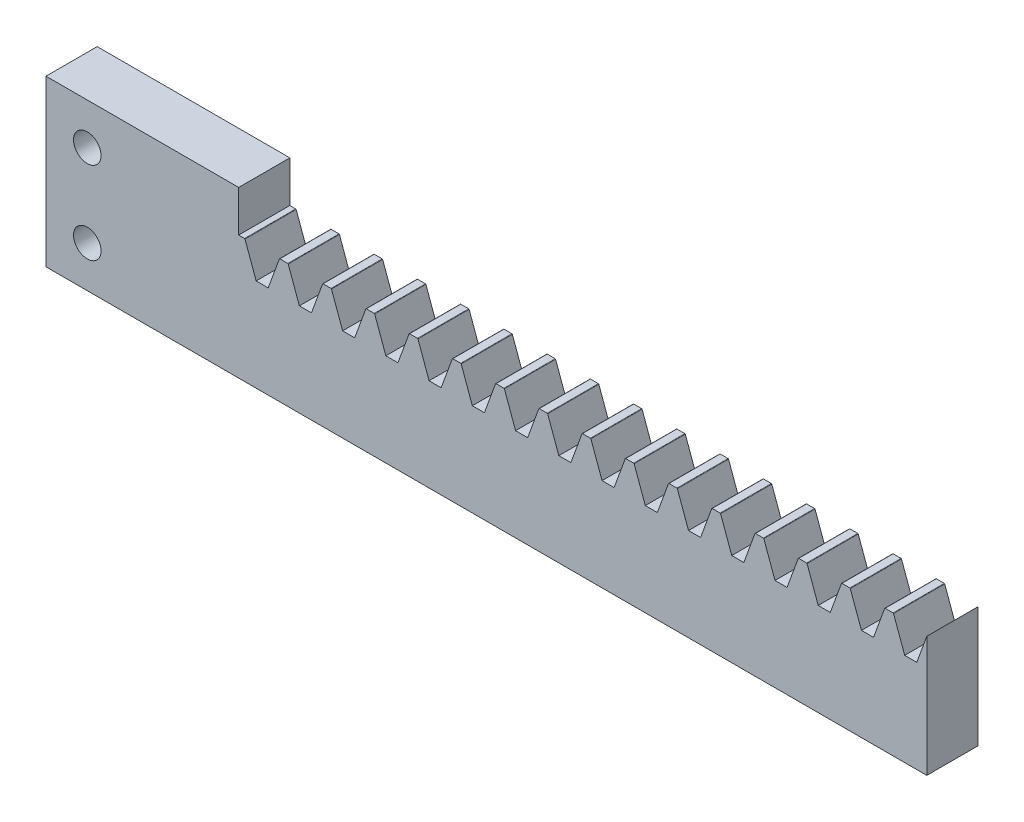
from build123d import *

# Parameters (mm, degrees)
BLANKSKE_W          = 203.2
BLANKSKE_H          = 28.575
BLANK_DEPTH         = 11.811
TOOTHCUTILL_DEPTH   = 12.811
TOOTHCUTSIM_DEPTH   = 12.811
TEETHCUTS_COUNT     = 22
TEETHCUTS_PITCH     = 9.974556664
SKETCH1_W           = 44.45
SKETCH1_H           = 38.1
BOSS_EXTRUDE1_DEPTH = 11.811
SKETCH2_R           = 3.175
CUT_EXTRUDE1_DEPTH  = 12.811


with BuildPart() as part:
    # BlankSke → Blank (new body)
    with BuildSketch(Plane.XY):
        with Locations((101.6, 14.2875)):
            Rectangle(BLANKSKE_W, BLANKSKE_H)
    extrude(amount=-BLANK_DEPTH)

    # TooCutSkeIll → ToothCutIll (cut, through all)
    with BuildSketch(Plane.XY):
        with BuildLine():
            Line((-3.961730054, 28.491436558), (-1.582427729, 21.954357146))
            ThreePointArc((-1.582427729, 21.954357146), (-1.29135804, 21.575027742), (-0.835353302, 21.43125))
            Line((-0.835353302, 21.43125), (0.835353302, 21.43125))
            ThreePointArc((0.835353302, 21.43125), (1.29135804, 21.575027742), (1.582427729, 21.954357146))
            Line((1.582427729, 21.954357146), (3.961730054, 28.491436558))
            ThreePointArc((3.961730054, 28.491436558), (4.00822681, 28.55203231), (4.081071017, 28.575))
            Line((4.081071017, 28.575), (4.081071017, 28.6004))
            Line((4.081071017, 28.6004), (-4.081071017, 28.6004))
            Line((-4.081071017, 28.6004), (-4.081071017, 28.575))
            ThreePointArc((-4.081071017, 28.575), (-4.00822681, 28.55203231), (-3.961730054, 28.491436558))
        make_face()
    toothcutill = extrude(amount=-TOOTHCUTILL_DEPTH, mode=Mode.SUBTRACT)

    # TooCutSkeSim → ToothCutSim (cut, through all)
    with BuildSketch(Plane.XY):
        Polygon((1.392032299, 21.43125), (-1.392032299, 21.43125), (-4.001389504, 28.6004), (4.001389504, 28.6004), align=None)
    toothcutsim = extrude(amount=-TOOTHCUTSIM_DEPTH, mode=Mode.SUBTRACT)

    # TeethCuts: ToothCutIll, ToothCutSim ×22
    with Locations(*[(i * TEETHCUTS_PITCH, 0, 0) for i in range(1, TEETHCUTS_COUNT)]):
        add(toothcutill, mode=Mode.SUBTRACT)
        add(toothcutsim, mode=Mode.SUBTRACT)

    # Sketch1 → Boss-Extrude1 (add)
    with BuildSketch(Plane.XY):
        with Locations((22.225, 19.05)):
            Rectangle(SKETCH1_W, SKETCH1_H)
    extrude(amount=-BOSS_EXTRUDE1_DEPTH)

    # Sketch2 → Cut-Extrude1 (cut, through all)
    with BuildSketch(Plane.XY):
        with Locations((9.525, 28.575)):
            Circle(SKETCH2_R)
        with Locations((9.525, 9.525)):
            Circle(SKETCH2_R)
    extrude(amount=-CUT_EXTRUDE1_DEPTH, mode=Mode.SUBTRACT)


solid = part.part
